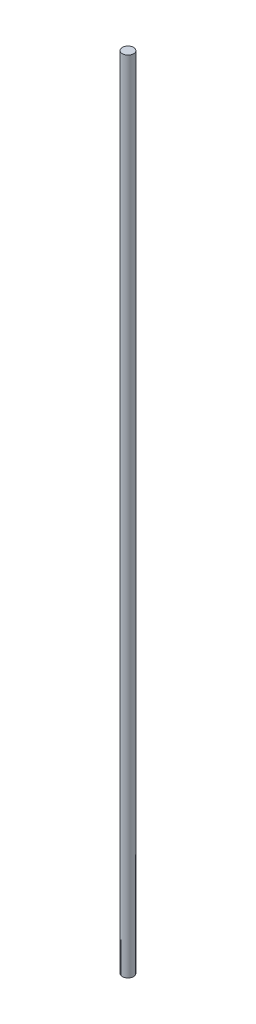
from build123d import *

# Parameters (mm, degrees)
ESQUISSE1_R        = 3
BOSS_EXTRU_1_DEPTH = 430


with BuildPart() as part:
    # Esquisse1 → Boss.-Extru.1 (new body)
    with BuildSketch(Plane(origin=(0, 0, 0), x_dir=(1, 0, 0), z_dir=(0, 1, 0))):
        Circle(ESQUISSE1_R)
    extrude(amount=BOSS_EXTRU_1_DEPTH)


solid = part.part
